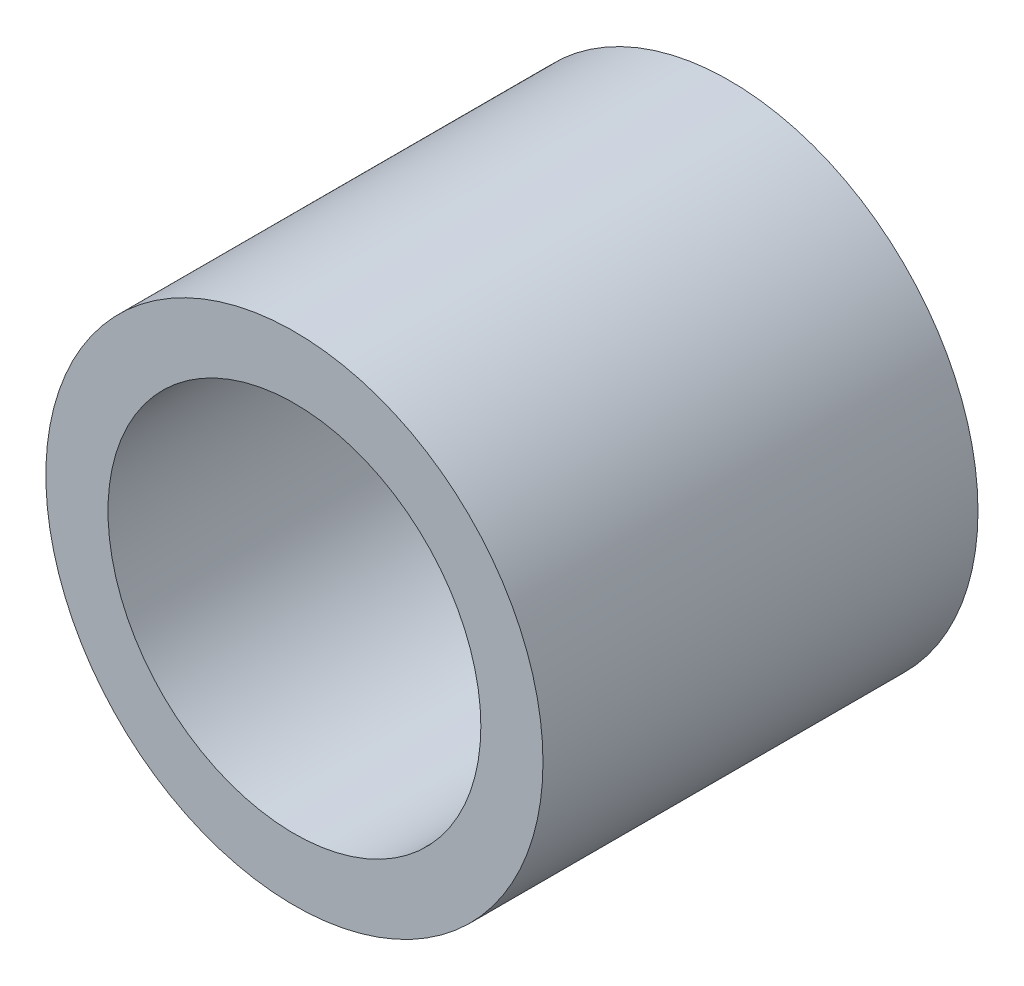
from build123d import *

# Parameters (mm, degrees)
SKETCH1_R           = 4
SKETCH1_R_2         = 1.9
BOSS_EXTRUDE1_DEPTH = 7
SKETCH2_R           = 3
CUT_EXTRUDE1_DEPTH  = 5


with BuildPart() as part:
    # Sketch1 → Boss-Extrude1 (new body)
    with BuildSketch(Plane.XY):
        Circle(SKETCH1_R)
        Circle(SKETCH1_R_2, mode=Mode.SUBTRACT)
    extrude(amount=BOSS_EXTRUDE1_DEPTH)

    # Sketch2 → Cut-Extrude1 (cut)
    with BuildSketch(Plane.XY.offset(7)):
        Circle(SKETCH2_R)
    extrude(amount=-CUT_EXTRUDE1_DEPTH, mode=Mode.SUBTRACT)


solid = part.part
